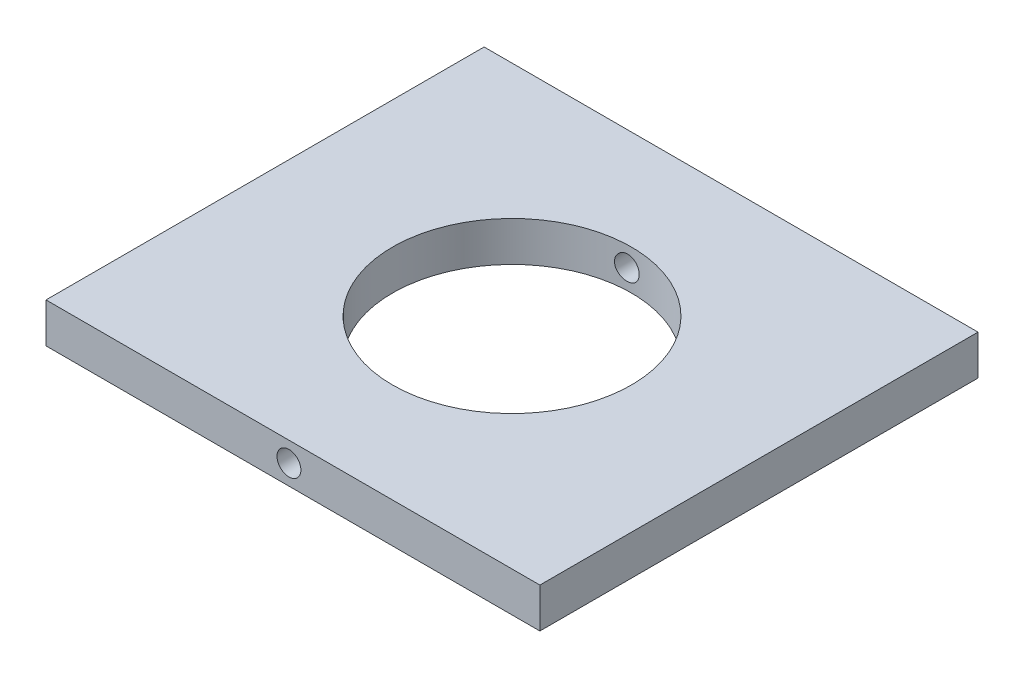
from build123d import *

# Parameters (mm, degrees)
ESQUISSE1_W             = 62
ESQUISSE1_H             = 5
BOSS_EXTRU_1_DEPTH      = 55
ESQUISSE2_R             = 15
ENL_V_MAT_EXTRU_1_DEPTH = 6
ESQUISSE5_R             = 1.5
ENL_V_MAT_EXTRU_4_DEPTH = 56


with BuildPart() as part:
    # Esquisse1 → Boss.-Extru.1 (new body)
    with BuildSketch(Plane.XY):
        with Locations((21.5, -47.5)):
            Rectangle(ESQUISSE1_W, ESQUISSE1_H)
    extrude(amount=BOSS_EXTRU_1_DEPTH)

    # Esquisse2 → Enlèv. mat.-Extru.1 (cut, through all)
    with BuildSketch(Plane(origin=(0, -45, 0), x_dir=(-1, 0, 0), z_dir=(0, 1, 0))):
        with Locations((-21.5, 27.5)):
            Circle(ESQUISSE2_R)
    extrude(amount=-ENL_V_MAT_EXTRU_1_DEPTH, mode=Mode.SUBTRACT)

    # Esquisse5 → Enlèv. mat.-Extru.4 (cut, through all)
    with BuildSketch(Plane.XY.offset(55)):
        with Locations((21, -47.5)):
            Circle(ESQUISSE5_R)
    extrude(amount=-ENL_V_MAT_EXTRU_4_DEPTH, mode=Mode.SUBTRACT)


solid = part.part
